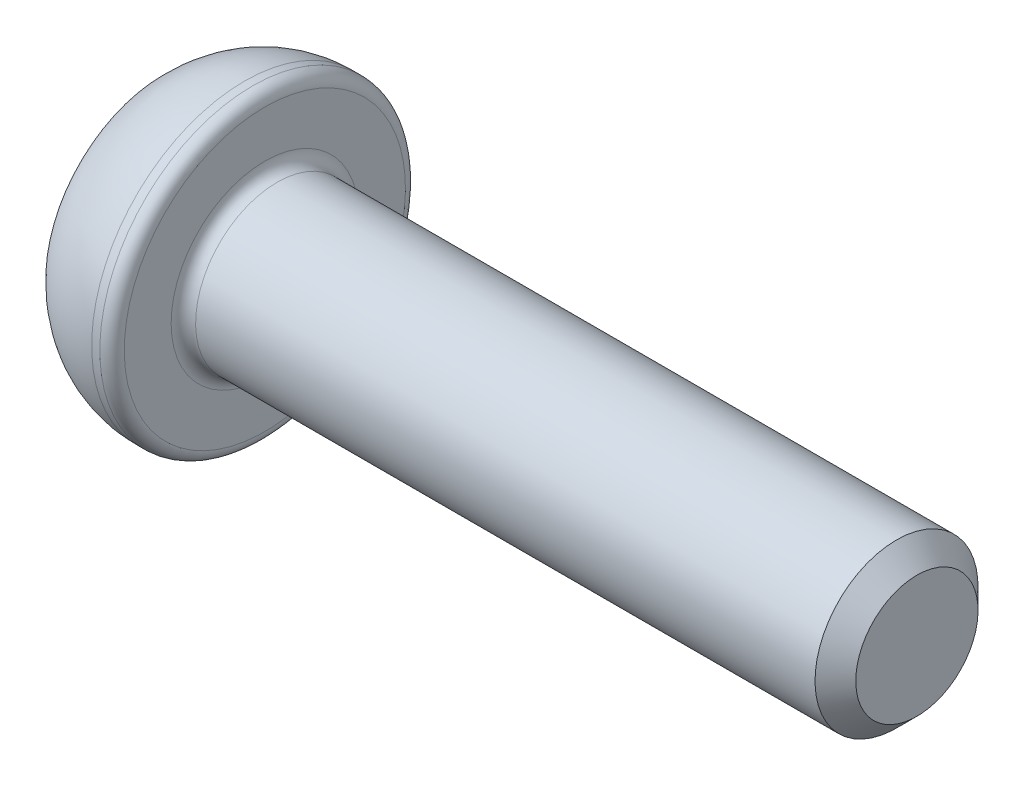
from build123d import *

# Parameters (mm, degrees)
CUT_EXTRUDE_1_DEPTH = 1.5
FILLET_1_R          = 0.3
CHAMFER_1_SIZE      = 0.5


with BuildPart() as part:
    # Эскиз1 → Повернуть1 (revolve)
    with BuildSketch(Plane.XY):
        with BuildLine():
            Line((0, 0), (0, 2.875))
            ThreePointArc((0, 2.875), (0.908484425, 3.521678457), (2, 3.75))
            Line((2, 3.75), (2.5, 3.75))
            Line((2.5, 3.75), (2.5, 2))
            Line((2.5, 2), (18.5, 2))
            Line((18.5, 2), (18.5, 0))
            Line((18.5, 0), (0, 0))
        make_face()
    revolve(axis=Axis((18.5, 0, 0), (-1, 0, 0)))

    # Эскиз2 → Вырез-Вытянуть1 (cut)
    with BuildSketch(Plane.ZY):
        Polygon((0.721687836, 1.25), (-0.721687836, 1.25), (-1.443375673, 0), (-0.721687836, -1.25), (0.721687836, -1.25), (1.443375673, 0), align=None)
    extrude(amount=-CUT_EXTRUDE_1_DEPTH, mode=Mode.SUBTRACT)

    # Скругление1
    fillet_1_edges = [part.edges().sort_by_distance(p)[0] for p in [
        (2.5, -2, 0),
        (2.5, -3.75, 0),
    ]]
    fillet(fillet_1_edges, radius=FILLET_1_R)

    # Фаска1
    chamfer_1_edges = [part.edges().sort_by_distance(p)[0] for p in [
        (18.5, -2, 0),
    ]]
    chamfer(chamfer_1_edges, length=CHAMFER_1_SIZE)


solid = part.part
